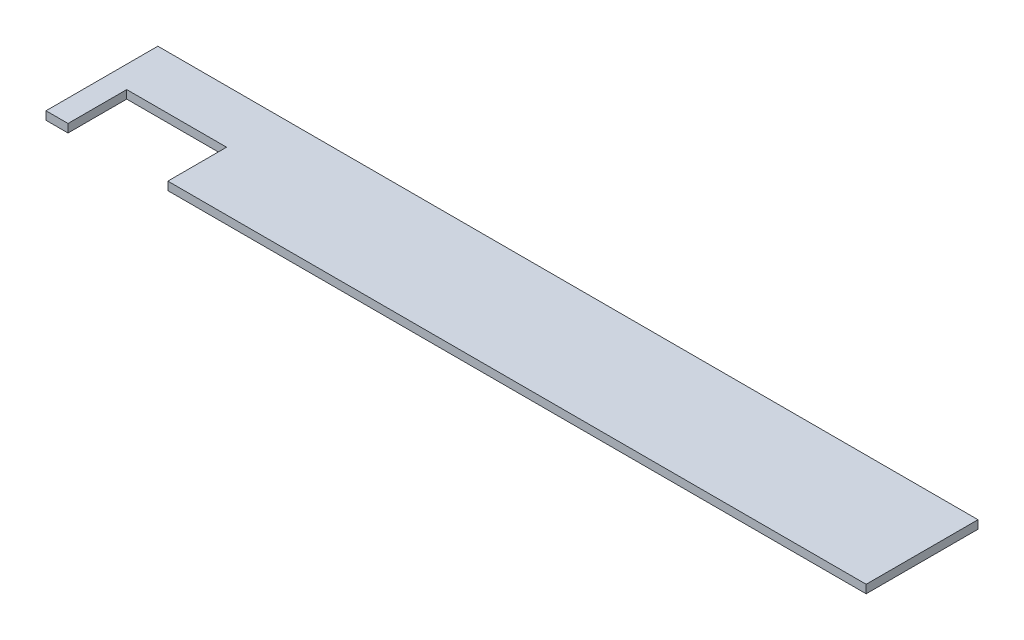
from build123d import *

# Parameters (mm, degrees)
BOSS_EXTRUDE1_DEPTH = 5.6388
SKETCH2_W           = 68
SKETCH2_H           = 40
CUT_EXTRUDE1_DEPTH  = 6.6388


with BuildPart() as part:
    # Sketch1 → Boss-Extrude1 (new body)
    with BuildSketch(Plane(origin=(0, 0, 0), x_dir=(1, 0, 0), z_dir=(0, 1, 0))):
        Polygon((-185, -73.025), (373.7224, -73.025), (373.7224, -6.825), (373.7224, 3.175), (175, 3.175), (-175, 3.175), (-185, 3.175), (-185, -6.825), align=None)
    extrude(amount=BOSS_EXTRUDE1_DEPTH)

    # Sketch2 → Cut-Extrude1 (cut, through all)
    with BuildSketch(Plane(origin=(0, 5.6388, 0), x_dir=(1, 0, 0), z_dir=(0, 1, 0))):
        with Locations((-136, -53.025)):
            Rectangle(SKETCH2_W, SKETCH2_H)
    extrude(amount=-CUT_EXTRUDE1_DEPTH, mode=Mode.SUBTRACT)


solid = part.part
